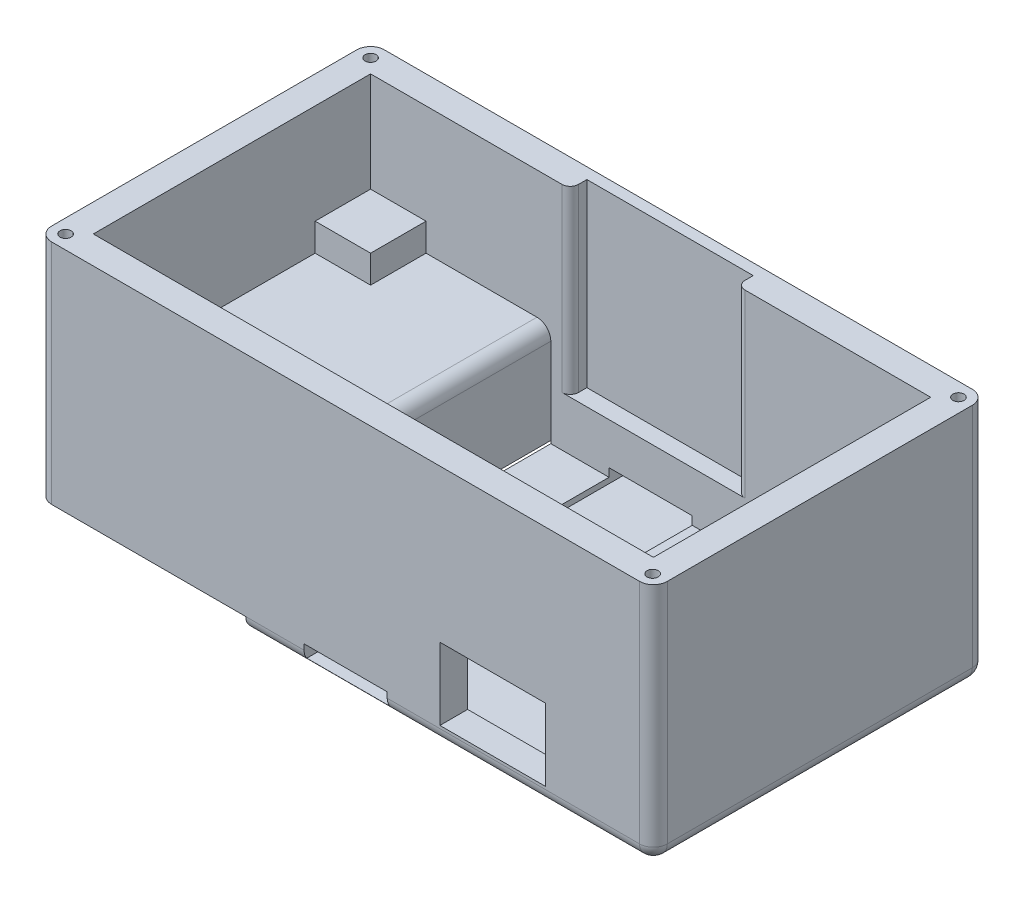
from build123d import *

# Parameters (mm, degrees)
SKETCH1_W           = 111
SKETCH1_H           = 60
BOSS_EXTRUDE1_DEPTH = 43.5
SKETCH2_W           = 101
SKETCH2_H           = 50
CUT_EXTRUDE1_DEPTH  = 18
CUT_EXTRUDE3_DEPTH  = 23
CUT_EXTRUDE5_START  = -2
SKETCH5_W           = 68.5
SKETCH5_H           = 50
CUT_EXTRUDE5_DEPTH  = 18.5
SKETCH6_W           = 37.5
SKETCH6_H           = 60
CUT_EXTRUDE6_DEPTH  = 2.5
SKETCH7_R           = 1
CUT_EXTRUDE7_DEPTH  = 4
SKETCH8_R           = 1
CUT_EXTRUDE8_DEPTH  = 4
SKETCH9_W           = 19
SKETCH9_H           = 13
CUT_EXTRUDE9_DEPTH  = 10
SKETCH12_W          = 30
SKETCH12_H          = 3
CUT_EXTRUDE12_DEPTH = 32.5
FILLET2_R           = 2.5
FILLET3_R           = 2.5
FILLET4_R           = 2.5
FILLET5_R           = 2.5
FILLET6_R           = 2.5
SKETCH13_W          = 27.5
SKETCH13_H          = 56
CUT_EXTRUDE13_DEPTH = 17
SKETCH14_W          = 15
SKETCH14_H          = 10
CUT_EXTRUDE14_DEPTH = 25
FILLET7_R           = 1.5
FILLET8_R           = 1.5
FILLET9_R           = 1.5
FILLET10_R          = 1.5
FILLET11_R          = 2.5
FILLET12_R          = 1.5
SKETCH15_W          = 22.107435613
SKETCH15_H          = 4.839639835
CUT_EXTRUDE15_DEPTH = 10
SKETCH16_W          = 15
SKETCH16_H          = 2.5
CUT_EXTRUDE16_DEPTH = 61


with BuildPart() as part:
    # Sketch1 → Boss-Extrude1 (new body)
    with BuildSketch(Plane(origin=(0, 0, 0), x_dir=(1, 0, 0), z_dir=(0, 1, 0))):
        with Locations((55.5, 30)):
            Rectangle(SKETCH1_W, SKETCH1_H)
    extrude(amount=BOSS_EXTRUDE1_DEPTH)

    # Sketch2 → Cut-Extrude1 (cut)
    with BuildSketch(Plane(origin=(0, 43.5, 0), x_dir=(1, 0, 0), z_dir=(0, 1, 0))):
        with Locations((55.5, 30)):
            Rectangle(SKETCH2_W, SKETCH2_H)
    extrude(amount=-CUT_EXTRUDE1_DEPTH, mode=Mode.SUBTRACT)

    # Sketch3 → Cut-Extrude3 (cut)
    with BuildSketch(Plane(origin=(0, 43.5, 0), x_dir=(1, 0, 0), z_dir=(0, 1, 0))):
        Polygon((5, 45), (15, 45), (15, 55), (96, 55), (96, 45), (106, 45), (106, 15), (96, 15), (96, 5), (15, 5), (15, 15), (5, 15), align=None)
    extrude(amount=-CUT_EXTRUDE3_DEPTH, mode=Mode.SUBTRACT)

    # Sketch5 → Cut-Extrude5 (cut)
    with BuildSketch(Plane.XZ.offset(CUT_EXTRUDE5_START)):
        with Locations((71.75, -30)):
            Rectangle(SKETCH5_W, SKETCH5_H)
    extrude(amount=-CUT_EXTRUDE5_DEPTH, mode=Mode.SUBTRACT)

    # Sketch6 → Cut-Extrude6 (cut)
    with BuildSketch(Plane.XZ):
        with Locations((18.75, -30)):
            Rectangle(SKETCH6_W, SKETCH6_H)
    extrude(amount=-CUT_EXTRUDE6_DEPTH, mode=Mode.SUBTRACT)

    # Sketch7 → Cut-Extrude7 (cut)
    with BuildSketch(Plane(origin=(0, 2.5, 0), x_dir=(-1, 0, 0), z_dir=(0, -1, 0))):
        with Locations((-2.5, 57.5)):
            Circle(SKETCH7_R)
        with Locations((-35, 57.5)):
            Circle(SKETCH7_R)
        with Locations((-35, 2.5)):
            Circle(SKETCH7_R)
        with Locations((-2.5, 2.5)):
            Circle(SKETCH7_R)
    extrude(amount=-CUT_EXTRUDE7_DEPTH, mode=Mode.SUBTRACT)

    # Sketch8 → Cut-Extrude8 (cut)
    with BuildSketch(Plane(origin=(0, 43.5, 0), x_dir=(1, 0, 0), z_dir=(0, 1, 0))):
        with Locations((2.5, 57.5)):
            Circle(SKETCH8_R)
        with Locations((108.5, 57.5)):
            Circle(SKETCH8_R)
        with Locations((108.5, 2.360383006)):
            Circle(SKETCH8_R)
        with Locations((2.5, 2.5)):
            Circle(SKETCH8_R)
    extrude(amount=-CUT_EXTRUDE8_DEPTH, mode=Mode.SUBTRACT)

    # Sketch9 → Cut-Extrude9 (cut)
    with BuildSketch(Plane.XY):
        with Locations((82, 9.5)):
            Rectangle(SKETCH9_W, SKETCH9_H)
    extrude(amount=-CUT_EXTRUDE9_DEPTH, mode=Mode.SUBTRACT)

    # Sketch12 → Cut-Extrude12 (cut)
    with BuildSketch(Plane(origin=(0, 43.5, 0), x_dir=(1, 0, 0), z_dir=(0, 1, 0))):
        with Locations((56, 56.5)):
            Rectangle(SKETCH12_W, SKETCH12_H)
    extrude(amount=-CUT_EXTRUDE12_DEPTH, mode=Mode.SUBTRACT)

    # Fillet2
    fillet2_edges = [part.edges().sort_by_distance(p)[0] for p in [
        (0, 23, 0),
    ]]
    fillet(fillet2_edges, radius=FILLET2_R)

    # Fillet3
    fillet3_edges = [part.edges().sort_by_distance(p)[0] for p in [
        (111, 21.75, 0),
    ]]
    fillet(fillet3_edges, radius=FILLET3_R)

    # Fillet4
    fillet4_edges = [part.edges().sort_by_distance(p)[0] for p in [
        (0, 23, -60),
    ]]
    fillet(fillet4_edges, radius=FILLET4_R)

    # Fillet5
    fillet5_edges = [part.edges().sort_by_distance(p)[0] for p in [
        (111, 21.75, -60),
    ]]
    fillet(fillet5_edges, radius=FILLET5_R)

    # Fillet6
    fillet6_edges = [part.edges().sort_by_distance(p)[0] for p in [
        (73, 0, -60),
        (110.267766953, 0, -59.267766953),
        (111, 0, -30),
        (110.267766953, 0, -0.732233047),
        (73, 0, 0),
    ]]
    fillet(fillet6_edges, radius=FILLET6_R)

    # Sketch13 → Cut-Extrude13 (cut)
    with BuildSketch(Plane.XZ.offset(-2.5)):
        with Locations((18.75, -30)):
            Rectangle(SKETCH13_W, SKETCH13_H)
    extrude(amount=-CUT_EXTRUDE13_DEPTH, mode=Mode.SUBTRACT)

    # Sketch14 → Cut-Extrude14 (cut, through all)
    with BuildSketch(Plane.XZ.offset(-19.5)):
        with Locations((24.5, -11.134142308)):
            Rectangle(SKETCH14_W, SKETCH14_H)
    extrude(amount=-CUT_EXTRUDE14_DEPTH, mode=Mode.SUBTRACT)

    # Fillet7
    fillet7_edges = [part.edges().sort_by_distance(p)[0] for p in [
        (32.5, 11, -2),
    ]]
    fillet(fillet7_edges, radius=FILLET7_R)

    # Fillet8
    fillet8_edges = [part.edges().sort_by_distance(p)[0] for p in [
        (5, 11, -2),
    ]]
    fillet(fillet8_edges, radius=FILLET8_R)

    # Fillet9
    fillet9_edges = [part.edges().sort_by_distance(p)[0] for p in [
        (32.5, 11, -58),
    ]]
    fillet(fillet9_edges, radius=FILLET9_R)

    # Fillet10
    fillet10_edges = [part.edges().sort_by_distance(p)[0] for p in [
        (5, 11, -58),
    ]]
    fillet(fillet10_edges, radius=FILLET10_R)

    # Fillet11
    fillet11_edges = [part.edges().sort_by_distance(p)[0] for p in [
        (37.5, 20.5, -30),
    ]]
    fillet(fillet11_edges, radius=FILLET11_R)

    # Fillet12
    fillet12_edges = [part.edges().sort_by_distance(p)[0] for p in [
        (71, 27.25, -55),
        (41, 27.25, -55),
    ]]
    fillet(fillet12_edges, radius=FILLET12_R)

    # Sketch15 → Cut-Extrude15 (cut)
    with BuildSketch(Plane(origin=(37.5, 0, 0), x_dir=(0, 0, -1), z_dir=(1, 0, 0))):
        with Locations((18.663805006, 13.487875839)):
            Rectangle(SKETCH15_W, SKETCH15_H)
    extrude(amount=-CUT_EXTRUDE15_DEPTH, mode=Mode.SUBTRACT)

    # Sketch16 → Cut-Extrude16 (cut, through all)
    with BuildSketch(Plane.XY):
        with Locations((55.5, 2.25)):
            Rectangle(SKETCH16_W, SKETCH16_H)
    extrude(amount=-CUT_EXTRUDE16_DEPTH, mode=Mode.SUBTRACT)


solid = part.part
